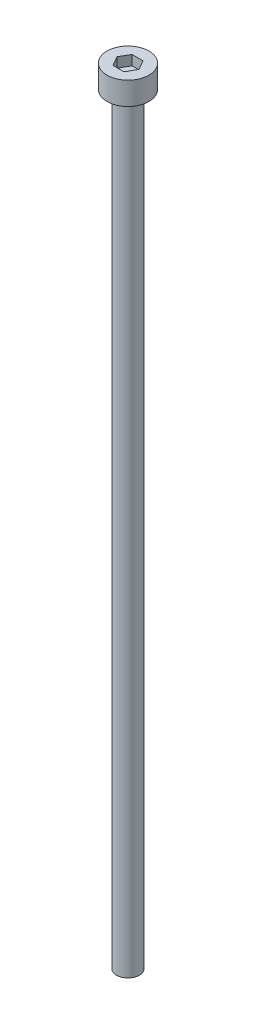
from build123d import *

# Parameters (mm, degrees)
SKETCH_1_R            = 2.75
EXTRUDE_248_DEPTH     = 3
CUT_EXTRUDE_378_DEPTH = 1.3
SKETCH_3_R            = 1.5
EXTRUDE_479_DEPTH     = 100


with BuildPart() as part:
    # 草图1 → Extrude 248 (new body)
    with BuildSketch(Plane(origin=(0, 0, 0), x_dir=(1, 0, 0), z_dir=(0, 1, 0))):
        Circle(SKETCH_1_R)
    extrude(amount=EXTRUDE_248_DEPTH)

    # 草图2 → Cut-Extrude 378 (cut)
    with BuildSketch(Plane(origin=(0, 3, 0), x_dir=(1, 0, 0), z_dir=(0, 1, 0))):
        Polygon((1.443375673, 0), (0.721687836, 1.25), (-0.721687836, 1.25), (-1.443375673, 0), (-0.721687836, -1.25), (0.721687836, -1.25), align=None)
    extrude(amount=-CUT_EXTRUDE_378_DEPTH, mode=Mode.SUBTRACT)

    # 草图3 → Extrude 479 (add)
    with BuildSketch(Plane.XZ):
        Circle(SKETCH_3_R)
    extrude(amount=EXTRUDE_479_DEPTH)


solid = part.part
